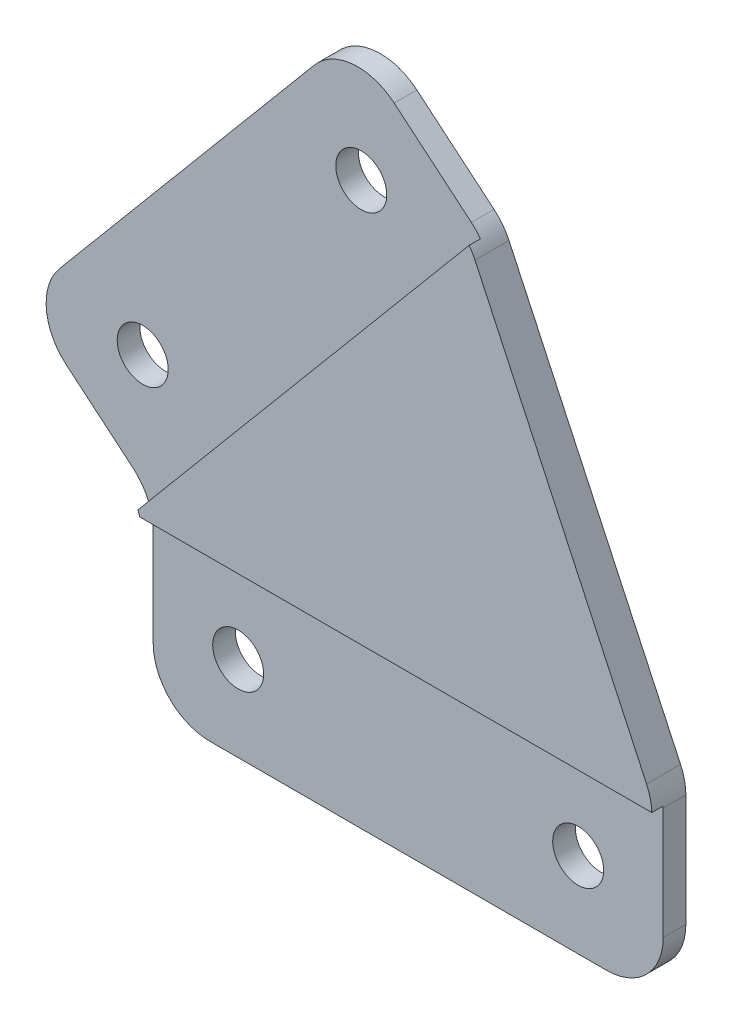
from build123d import *

# Parameters (mm, degrees)
EXTRUDE_1_DEPTH     = 3
SKETCH_2_R          = 2.25
CUT_EXTRUDE_1_DEPTH = 3
FILLET_1_R          = 5
SKETCH_3_W          = 46
SKETCH_3_H          = 15.05
CUT_EXTRUDE_2_DEPTH = 1


with BuildPart() as part:
    # ｽｹｯﾁ1 → ﾎﾞｽ - 押し出し1 (new body)
    with BuildSketch(Plane.XY):
        Polygon((17.434775789, 44.113814086), (-11.490666647, 9.641814145), (0, 0), (0, -16), (45, -16), (45, 0), (28.925442436, 34.47199994), align=None)
    extrude(amount=EXTRUDE_1_DEPTH)

    # ｽｹｯﾁ2 → ｶｯﾄ - 押し出し1 (cut)
    with BuildSketch(Plane.XY.offset(3)):
        with Locations((7.5, -8.5)):
            Circle(SKETCH_2_R)
        with Locations((-0.924426251, 10.566240396)):
            Circle(SKETCH_2_R)
        with Locations((18.35920204, 33.54757369)):
            Circle(SKETCH_2_R)
        with Locations((37.5, -8.5)):
            Circle(SKETCH_2_R)
    extrude(amount=-CUT_EXTRUDE_1_DEPTH, mode=Mode.SUBTRACT)

    # ﾌｨﾚｯﾄ1
    fillet_1_edges = [part.edges().sort_by_distance(p)[0] for p in [
        (17.434775789, 44.113814086, 1.5),
        (28.925442436, 34.47199994, 1.5),
        (45, 0, 1.5),
        (45, -16, 1.5),
        (0, -16, 1.5),
        (0, 0, 1.5),
        (-11.490666647, 9.641814145, 1.5),
    ]]
    fillet(fillet_1_edges, radius=FILLET_1_R)

    # ｽｹｯﾁ3 → ｶｯﾄ - 押し出し2 (cut)
    with BuildSketch(Plane.XY.offset(3)):
        Polygon((17.434775789, 44.113814086), (-12.133454256, 8.875769702), (-0.604485388, -0.798183824), (28.963744658, 34.43986056), align=None)
        with Locations((22, -8.475)):
            Rectangle(SKETCH_3_W, SKETCH_3_H)
    extrude(amount=-CUT_EXTRUDE_2_DEPTH, mode=Mode.SUBTRACT)


solid = part.part
